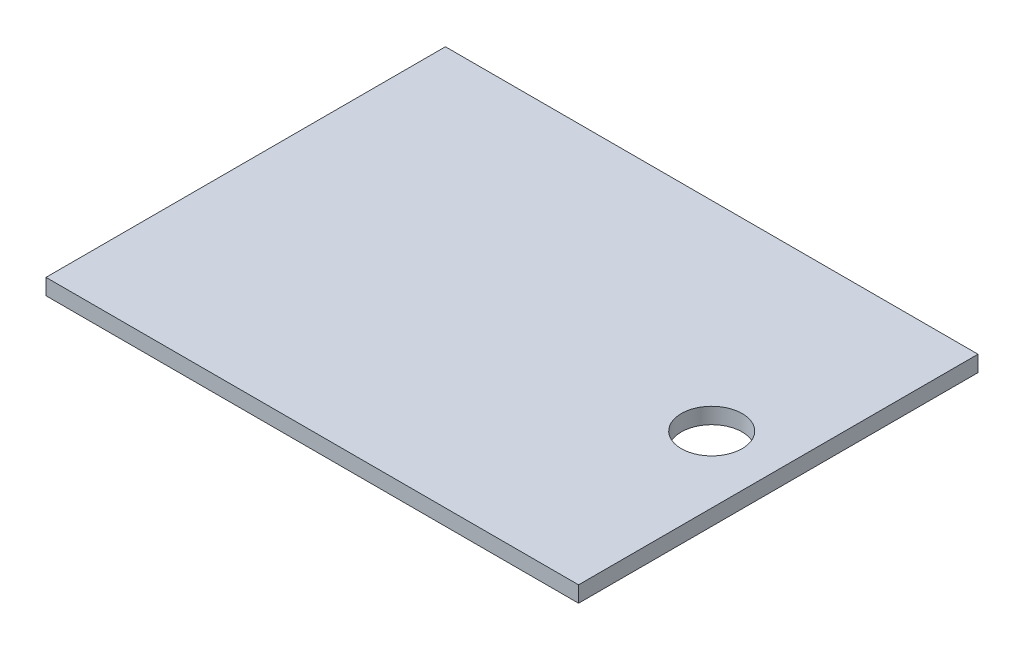
from build123d import *

# Parameters (mm, degrees)
SKETCH1_W           = 200
SKETCH1_H           = 150
SKETCH1_R           = 11.43
BOSS_EXTRUDE1_DEPTH = 6


with BuildPart() as part:
    # Sketch1 → Boss-Extrude1 (new body)
    with BuildSketch(Plane(origin=(0, 0, 0), x_dir=(1, 0, 0), z_dir=(0, 1, 0))):
        Rectangle(SKETCH1_W, SKETCH1_H)
        with Locations((75, 0)):
            Circle(SKETCH1_R, mode=Mode.SUBTRACT)
    extrude(amount=BOSS_EXTRUDE1_DEPTH)


solid = part.part
